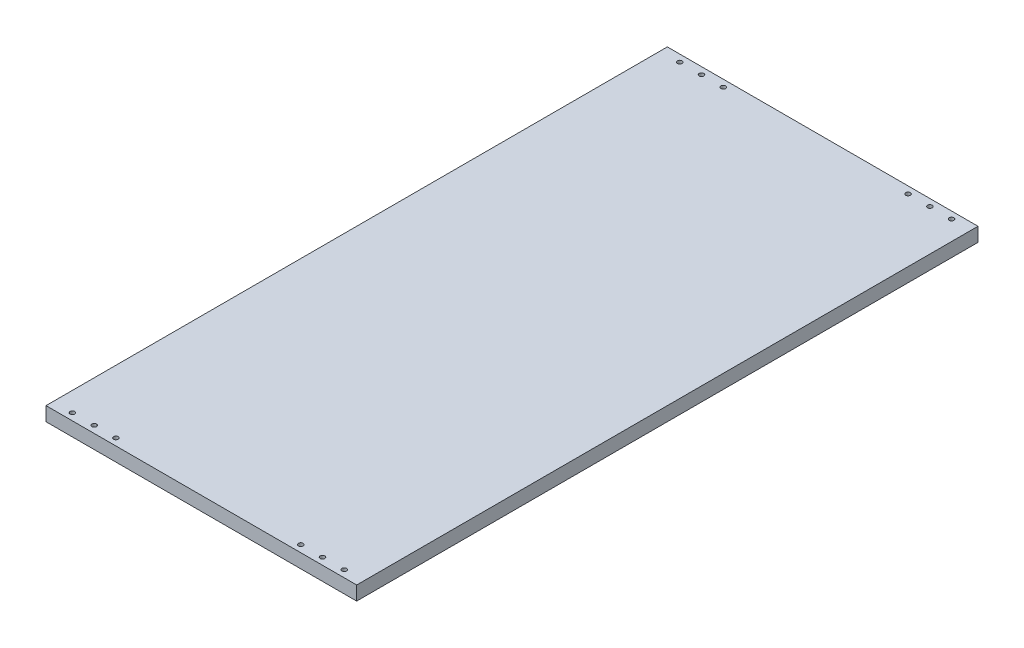
from build123d import *

# Parameters (mm, degrees)
SKETCH_1_W          = 400
SKETCH_1_H          = 800
EXTRUDE_1_DEPTH     = 18
SKETCH_2_R          = 3
CUT_EXTRUDE_1_DEPTH = 9


with BuildPart() as part:
    # Эскиз1 → Бобышка-Вытянуть1 (new body)
    with BuildSketch(Plane(origin=(0, 0, 0), x_dir=(1, 0, 0), z_dir=(0, 1, 0))):
        with Locations((200, 400)):
            Rectangle(SKETCH_1_W, SKETCH_1_H)
    extrude(amount=EXTRUDE_1_DEPTH)

    # Эскиз2 → Вырез-Вытянуть1 (cut)
    with BuildSketch(Plane(origin=(0, 18, 0), x_dir=(1, 0, 0), z_dir=(0, 1, 0))):
        with Locations((25, 9)):
            Circle(SKETCH_2_R)
        with Locations((53, 9)):
            Circle(SKETCH_2_R)
        with Locations((81, 9)):
            Circle(SKETCH_2_R)
        with Locations((319, 9)):
            Circle(SKETCH_2_R)
        with Locations((347, 9)):
            Circle(SKETCH_2_R)
        with Locations((375, 9)):
            Circle(SKETCH_2_R)
        with Locations((375, 791)):
            Circle(SKETCH_2_R)
        with Locations((347, 791)):
            Circle(SKETCH_2_R)
        with Locations((319, 791)):
            Circle(SKETCH_2_R)
        with Locations((81, 791)):
            Circle(SKETCH_2_R)
        with Locations((53, 791)):
            Circle(SKETCH_2_R)
        with Locations((25, 791)):
            Circle(SKETCH_2_R)
    extrude(amount=-CUT_EXTRUDE_1_DEPTH, mode=Mode.SUBTRACT)


solid = part.part
